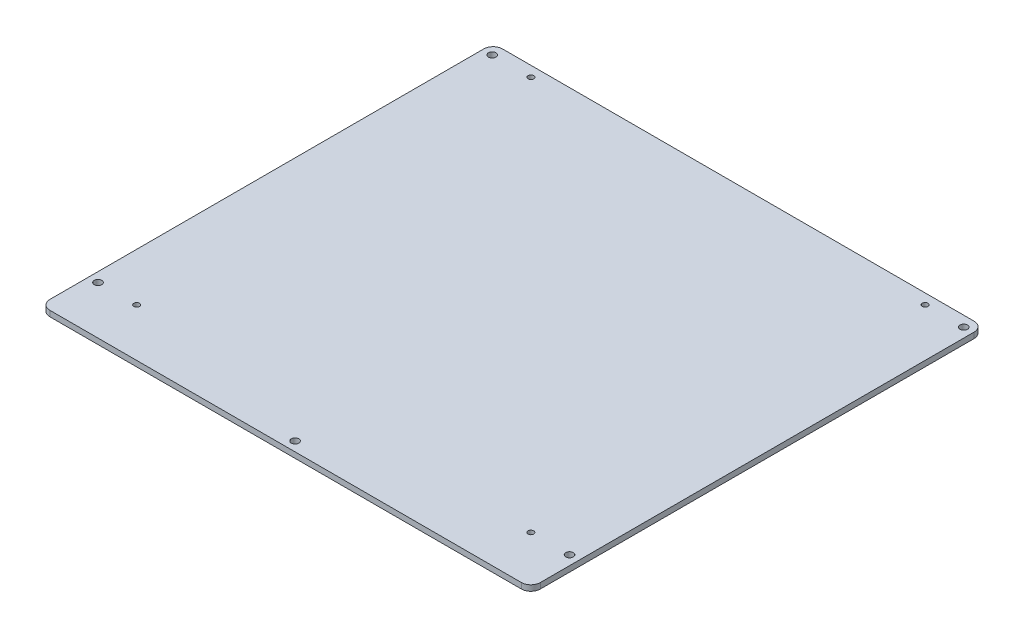
from build123d import *

# Parameters (mm, degrees)
CROQUIS1_W              = 260
CROQUIS1_H              = 240
CROQUIS1_R              = 1.5
CROQUIS1_R_2            = 2
SALIENTE_EXTRUIR1_DEPTH = 3
REDONDEO1_R             = 5


with BuildPart() as part:
    # Croquis1 → Saliente-Extruir1 (new body)
    with BuildSketch(Plane(origin=(0, 0, 0), x_dir=(1, 0, 0), z_dir=(0, 1, 0))):
        with Locations((0, -10)):
            Rectangle(CROQUIS1_W, CROQUIS1_H)
        with Locations((-104.5, 104.5)):
            Circle(CROQUIS1_R, mode=Mode.SUBTRACT)
        with Locations((104.5, 104.5)):
            Circle(CROQUIS1_R, mode=Mode.SUBTRACT)
        with Locations((-104.5, -104.5)):
            Circle(CROQUIS1_R, mode=Mode.SUBTRACT)
        with Locations((104.5, -104.5)):
            Circle(CROQUIS1_R, mode=Mode.SUBTRACT)
        with Locations((125, 104.5)):
            Circle(CROQUIS1_R_2, mode=Mode.SUBTRACT)
        with Locations((125, -104.5)):
            Circle(CROQUIS1_R_2, mode=Mode.SUBTRACT)
        with Locations((-125, -104.5)):
            Circle(CROQUIS1_R_2, mode=Mode.SUBTRACT)
        with Locations((-125, 104.5)):
            Circle(CROQUIS1_R_2, mode=Mode.SUBTRACT)
        with Locations((0, -125)):
            Circle(CROQUIS1_R_2, mode=Mode.SUBTRACT)
    extrude(amount=SALIENTE_EXTRUIR1_DEPTH)

    # Redondeo1
    redondeo1_edges = [part.edges().sort_by_distance(p)[0] for p in [
        (-130, 1.5, -110),
        (130, 1.5, -110),
        (130, 1.5, 130),
        (-130, 1.5, 130),
    ]]
    fillet(redondeo1_edges, radius=REDONDEO1_R)


solid = part.part
